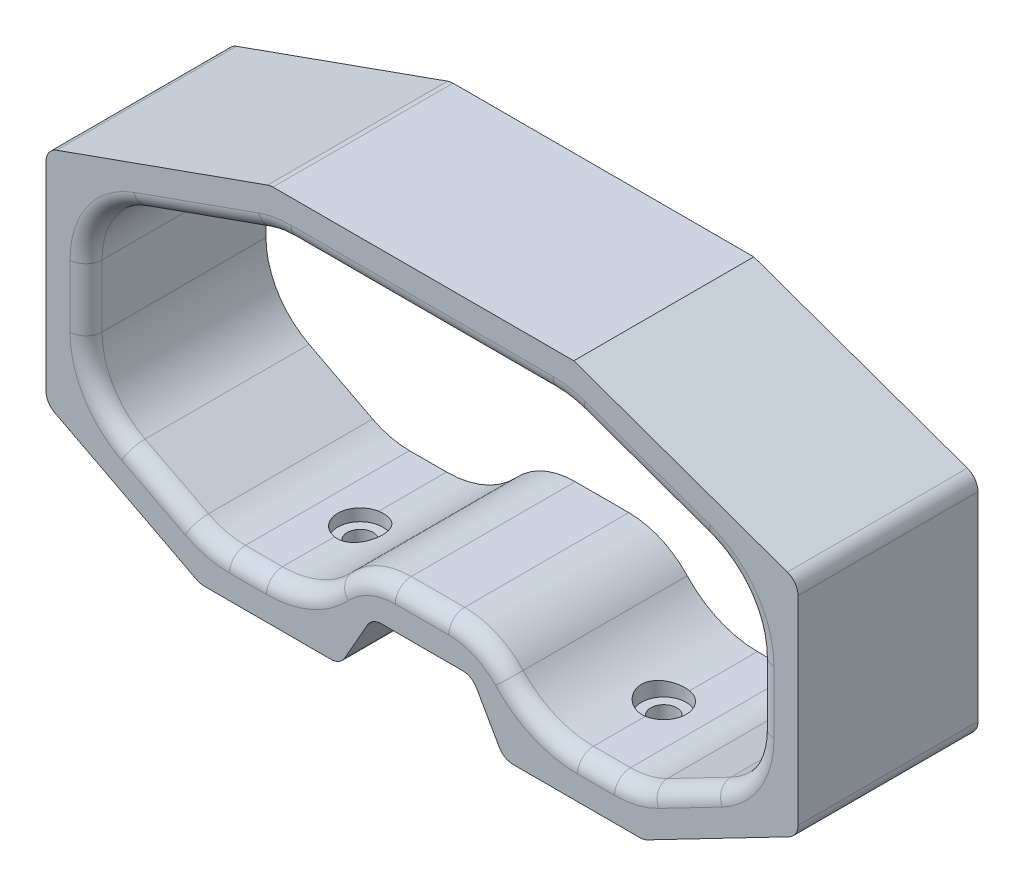
from build123d import *

# Parameters (mm, degrees)
BOSS_EXTRUDE1_DEPTH = 22.5
FILLET1_R           = 12
CUT_EXTRUDE1_START  = 5.5
SCREW_MOUNT_R       = 2.8
SCREW_MOUNT_R_2     = 1.625
CUT_EXTRUDE1_DEPTH  = 2
CUT_EXTRUDE2_START  = 5
SCREW_MOUNT_3_R     = 1.625
CUT_EXTRUDE2_DEPTH  = 76.508864857
FILLET3_R           = 2
FILLET4_R           = 2


with BuildPart() as part:
    # Base → Boss-Extrude1 (new body)
    with BuildSketch(Plane.XY):
        Polygon((-27.725, 0), (-10.225, 0), (-6.25, 7), (6.25, 7), (10.225, 0), (27.725, 0), (47, 10), (47, 37.5), (18.975, 47.5), (-18.975, 47.5), (-47, 37.5), (-47, 10), align=None)
        with BuildLine():
            Line((-28.670726654, 6.123500417), (-36.605187851, 10.2399524))
            ThreePointArc((-36.605187851, 10.2399524), (-40.545521591, 13.922796166), (-42, 19.116451983))
            Line((-42, 19.116451983), (-42, 26.926039841))
            ThreePointArc((-42, 26.926039841), (-40.17334162, 32.687679084), (-35.360702646, 36.344409006))
            Line((-35.360702646, 36.344409006), (-19.7396793, 41.918369165))
            ThreePointArc((-19.7396793, 41.918369165), (-18.084307759, 42.353519464), (-16.378976654, 42.5))
            Line((-16.378976654, 42.5), (16.378976654, 42.5))
            ThreePointArc((16.378976654, 42.5), (18.084307759, 42.353519464), (19.7396793, 41.918369165))
            Line((19.7396793, 41.918369165), (35.360702646, 36.344409006))
            ThreePointArc((35.360702646, 36.344409006), (40.17334162, 32.687679084), (42, 26.926039841))
            Line((42, 26.926039841), (42, 19.116451983))
            ThreePointArc((42, 19.116451983), (40.545521591, 13.922796166), (36.605187851, 10.2399524))
            Line((36.605187851, 10.2399524), (28.670726654, 6.123500417))
            ThreePointArc((28.670726654, 6.123500417), (26.435665821, 5.284934487), (24.065538803, 5))
            Line((24.065538803, 5), (13.1356311, 5))
            Line((13.1356311, 5), (12.035146877, 6.937959637))
            ThreePointArc((12.035146877, 6.937959637), (8.370293449, 10.642325971), (3.3393689, 12))
            Line((3.3393689, 12), (-3.3393689, 12))
            ThreePointArc((-3.3393689, 12), (-8.370293449, 10.642325971), (-12.035146877, 6.937959637))
            Line((-12.035146877, 6.937959637), (-13.1356311, 5))
            Line((-13.1356311, 5), (-24.065538803, 5))
            ThreePointArc((-24.065538803, 5), (-26.435665821, 5.284934487), (-28.670726654, 6.123500417))
        make_face(mode=Mode.SUBTRACT)
    extrude(amount=BOSS_EXTRUDE1_DEPTH)

    # Fillet1
    fillet1_edges = [part.edges().sort_by_distance(p)[0] for p in [
        (13.1356311, 5, 11.25),
        (-13.1356311, 5, 11.25),
    ]]
    fillet(fillet1_edges, radius=FILLET1_R)

    # Screw_Mount → Cut-Extrude1 (cut)
    with BuildSketch(Plane(origin=(0, 0, 0), x_dir=(1, 0, 0), z_dir=(0, 1, 0)).offset(CUT_EXTRUDE1_START)):
        with Locations(Location((-18.975, -11.25, 0), (0, 0, 270))):
            Circle(SCREW_MOUNT_R)
        with Locations((-18.975, -11.25)):
            Circle(SCREW_MOUNT_R_2, mode=Mode.SUBTRACT)
        with Locations((-18.975, -11.25)):
            Circle(SCREW_MOUNT_R_2)
        with Locations(Location((18.975, -11.25, 0), (0, 0, 270))):
            Circle(SCREW_MOUNT_R)
        with Locations((18.975, -11.25)):
            Circle(SCREW_MOUNT_R_2, mode=Mode.SUBTRACT)
        with Locations((18.975, -11.25)):
            Circle(SCREW_MOUNT_R_2)
    extrude(amount=-CUT_EXTRUDE1_DEPTH, mode=Mode.SUBTRACT)

    # Screw_Mount_3 → Cut-Extrude2 (cut, through all)
    with BuildSketch(Plane(origin=(0, 0, 0), x_dir=(1, 0, 0), z_dir=(0, 1, 0)).offset(CUT_EXTRUDE2_START)):
        with Locations(Location((-18.975, -11.25, 0), (0, 0, 270))):
            Circle(SCREW_MOUNT_3_R)
        with Locations(Location((18.975, -11.25, 0), (0, 0, 270))):
            Circle(SCREW_MOUNT_3_R)
    extrude(amount=-CUT_EXTRUDE2_DEPTH, mode=Mode.SUBTRACT)

    # Fillet3
    fillet3_edges = [part.edges().sort_by_distance(p)[0] for p in [
        (-47, 10, 11.25),
        (-47, 37.5, 11.25),
        (-18.975, 47.5, 11.25),
        (47, 37.5, 11.25),
        (47, 10, 11.25),
        (27.725, 0, 11.25),
        (10.225, 0, 11.25),
        (6.25, 7, 11.25),
        (-6.25, 7, 11.25),
        (-10.225, 0, 11.25),
        (-27.725, 0, 11.25),
    ]]
    fillet(fillet3_edges, radius=FILLET3_R)

    # Fillet4
    fillet4_edges = [part.edges().sort_by_distance(p)[0] for p in [
        (21.749192321, 5, 22.5),
        (-7.327989076, 11.170109546, 22.5),
        (14.646501628, 5.995868544, 22.5),
        (-14.646501628, 5.995868544, 22.5),
        (26.435665821, 5.284934487, 22.5),
        (32.637957253, 8.181726408, 22.5),
        (40.545521591, 13.922796166, 22.5),
        (42, 23.021245912, 22.5),
        (40.17334162, 32.687679084, 22.5),
        (27.550190973, 39.131389085, 22.5),
        (18.084307759, 42.353519464, 22.5),
        (0, 42.5, 22.5),
        (-18.084307759, 42.353519464, 22.5),
        (-27.550190973, 39.131389085, 22.5),
        (-40.17334162, 32.687679084, 22.5),
        (-42, 23.021245912, 22.5),
        (-40.545521591, 13.922796166, 22.5),
        (-32.637957253, 8.181726408, 22.5),
        (-26.435665821, 5.284934487, 22.5),
        (-21.749192321, 5, 22.5),
        (0, 12, 22.5),
        (7.327989076, 11.170109546, 22.5),
    ]]
    fillet(fillet4_edges, radius=FILLET4_R)


solid = part.part
